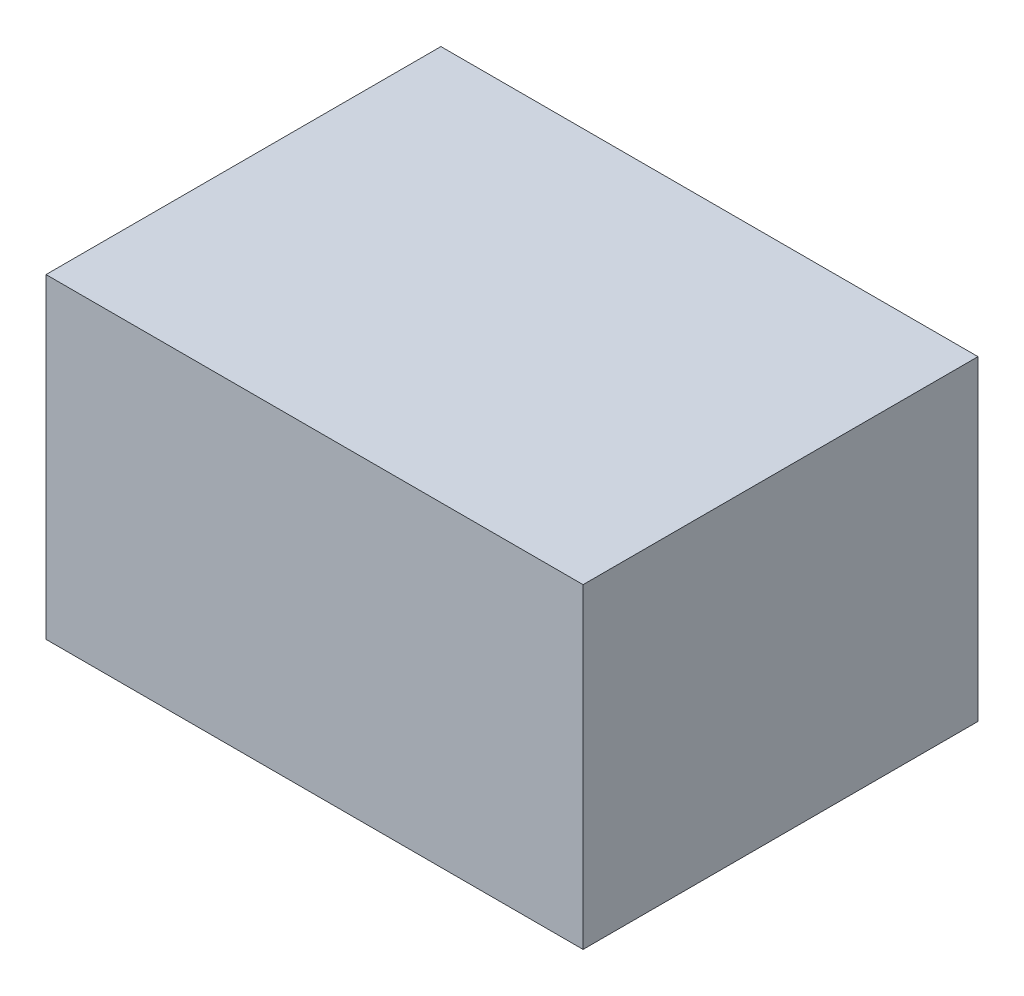
from build123d import *

# Parameters (mm, degrees)
SKETCH1_W           = 340
SKETCH1_H           = 250
BOSS_EXTRUDE1_DEPTH = 200


with BuildPart() as part:
    # Sketch1 → Boss-Extrude1 (new body)
    with BuildSketch(Plane(origin=(0, 0, 0), x_dir=(1, 0, 0), z_dir=(0, 1, 0))):
        with Locations((170, 125)):
            Rectangle(SKETCH1_W, SKETCH1_H)
    extrude(amount=BOSS_EXTRUDE1_DEPTH)


solid = part.part
